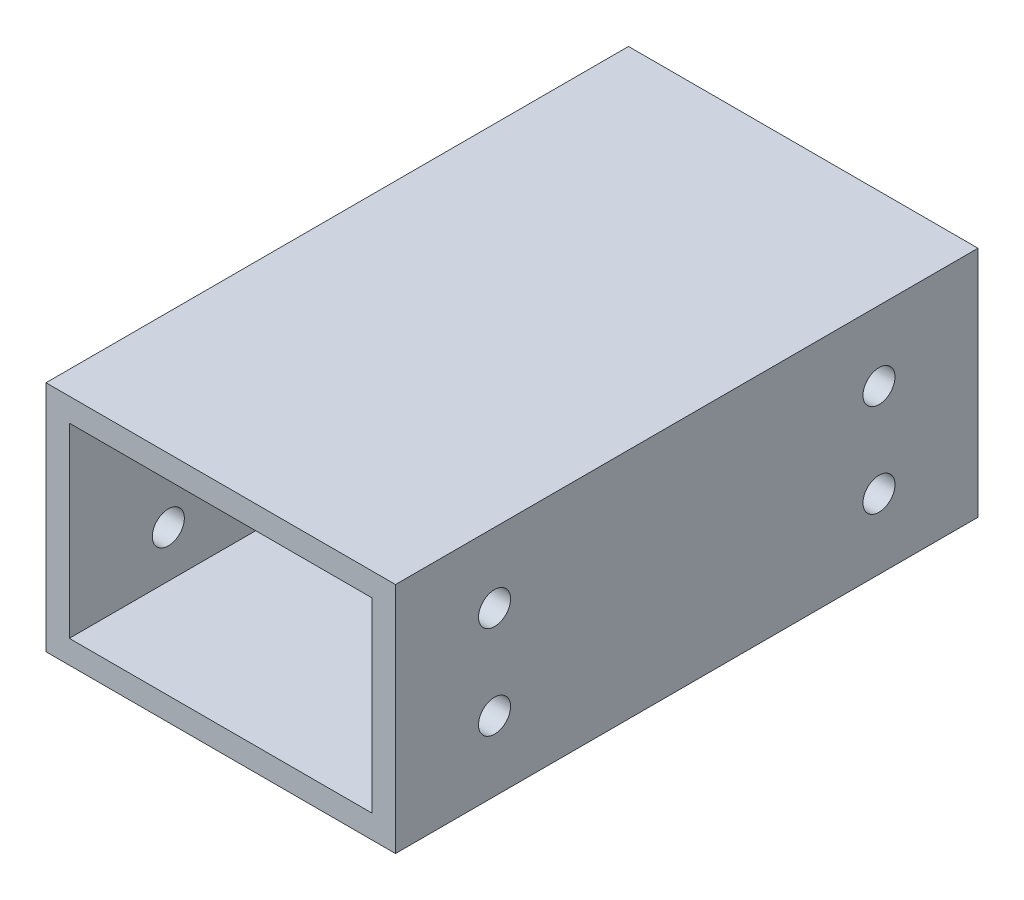
from build123d import *

# Parameters (mm, degrees)
EXTRUDE_3_DEPTH         = 50
EXTRUDE_3_DEPTH_BACK    = 50
SKETCH_2_W              = 60
SKETCH_2_H              = 40
SKETCH_2_W_2            = 52
SKETCH_2_H_2            = 32
HOLE_WIZARD_5_5_5_5_1_D = 5.5


with BuildPart() as part:
    # Эскиз2 → Бобышка-Вытянуть3 (new, two sides: drawn at the far end of the back side and taken through both)
    with BuildSketch(Plane.XY.offset(-EXTRUDE_3_DEPTH_BACK)):
        Rectangle(SKETCH_2_W, SKETCH_2_H)
        Rectangle(SKETCH_2_W_2, SKETCH_2_H_2, mode=Mode.SUBTRACT)
    extrude(amount=EXTRUDE_3_DEPTH + EXTRUDE_3_DEPTH_BACK)

    # Диаметр отверстия Ø5.5 (5.5)1 (through all)
    with Locations(Plane.ZY.offset(30)):
        with Locations((-33, 8), (-33, -8), (33, 8), (33, -8)):
            Hole(HOLE_WIZARD_5_5_5_5_1_D / 2)


solid = part.part
